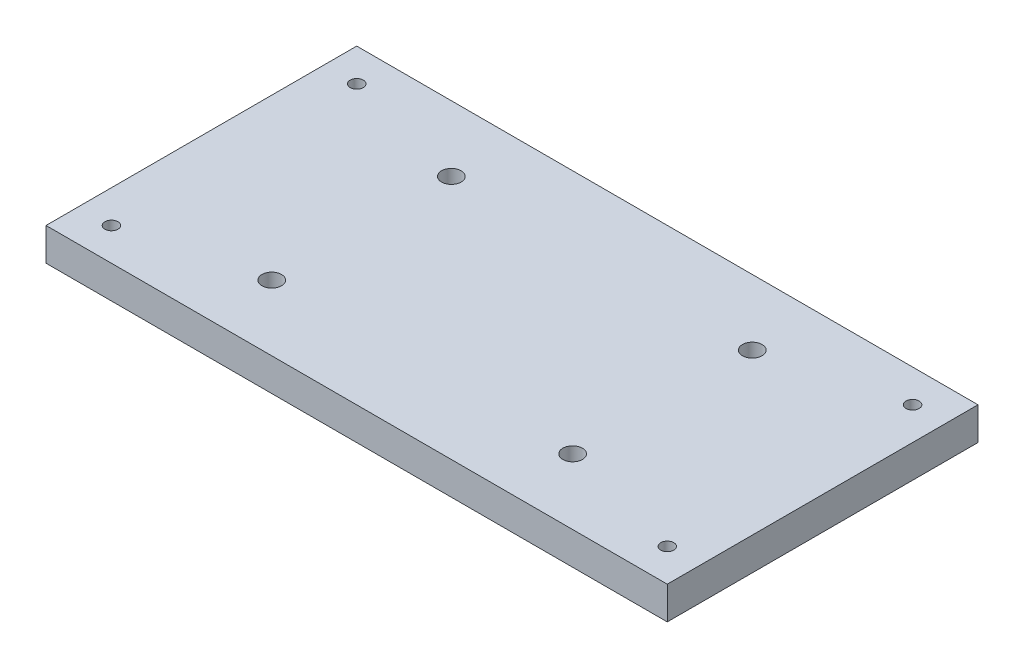
from build123d import *

# Parameters (mm, degrees)
SKETCH2_R           = 2
SKETCH2_R_2         = 3
BOSS_EXTRUDE1_DEPTH = 10
SKETCH2_4_R         = 3
CUT_EXTRUDE1_DEPTH  = 35


with BuildPart() as part:
    # Sketch2 → Boss-Extrude1 (new body)
    with BuildSketch(Plane(origin=(0, 0, 0), x_dir=(1, 0, 0), z_dir=(0, 1, 0))):
        Polygon((-91.36726229, 42.291495859), (-101.36726229, 42.291495859), (-101.36726229, -52.708504141), (88.58273771, -52.708504141), (88.58273771, 42.291495859), align=None)
        with Locations((-91.36726229, -42.708504141)):
            Circle(SKETCH2_R, mode=Mode.SUBTRACT)
        with Locations((-52.39226229, -32.668504141)):
            Circle(SKETCH2_R_2, mode=Mode.SUBTRACT)
        with Locations((-52.39226229, 22.251495859)):
            Circle(SKETCH2_R_2, mode=Mode.SUBTRACT)
        with Locations((-91.36726229, 32.291495859)):
            Circle(SKETCH2_R, mode=Mode.SUBTRACT)
        with Locations((39.60773771, 22.251495859)):
            Circle(SKETCH2_R_2, mode=Mode.SUBTRACT)
        with Locations((78.58273771, 32.291495859)):
            Circle(SKETCH2_R, mode=Mode.SUBTRACT)
        with Locations((78.58273771, -42.708504141)):
            Circle(SKETCH2_R, mode=Mode.SUBTRACT)
    extrude(amount=BOSS_EXTRUDE1_DEPTH)

    # Sketch2_4 → Cut-Extrude1 (cut)
    with BuildSketch(Plane(origin=(0, 0, 0), x_dir=(1, 0, 0), z_dir=(0, 1, 0))):
        with Locations((39.60773771, -32.668504141)):
            Circle(SKETCH2_4_R)
    extrude(amount=CUT_EXTRUDE1_DEPTH, mode=Mode.SUBTRACT)


solid = part.part
